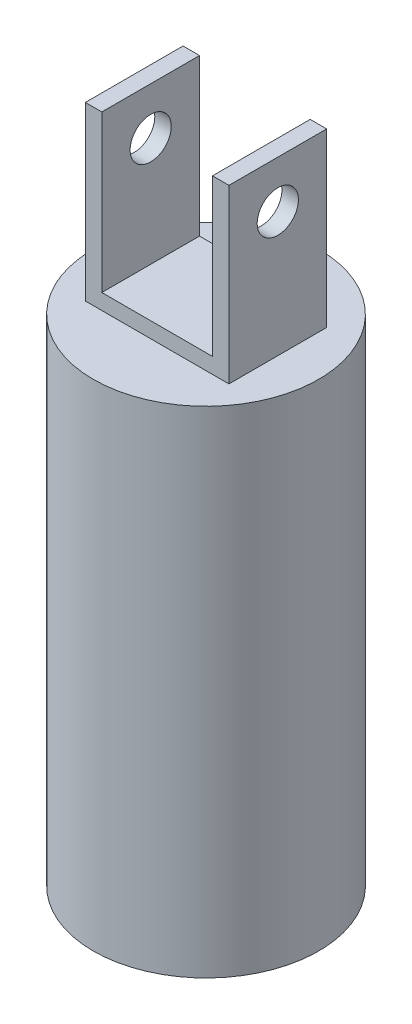
from build123d import *

# Parameters (mm, degrees)
SKETCH1_W           = 4.826
SKETCH1_H           = 25.19045
BOSS_EXTRUDE1_DEPTH = 28.6258
SKETCH2_R           = 25.4
BOSS_EXTRUDE2_DEPTH = 145.034
SKETCH4_R           = 33.02
BOSS_EXTRUDE3_DEPTH = 145.034
SKETCH5_R           = 6.0325
CUT_EXTRUDE2_DEPTH  = 55.0512
SKETCH6_R           = 19.812
CUT_EXTRUDE3_DEPTH  = 106.934


with BuildPart() as part:
    # Sketch1 → Boss-Extrude1 (new body)
    with BuildSketch(Plane.XY):
        Polygon((37.2364, 24.806452693), (42.0624, 24.806452693), (42.0624, 50.3809), (37.2364, 50.3809), (37.2364, 25.19045), align=None)
        Polygon((21.0312, 4.572), (21.0312, 0), (42.0624, 0), (42.0624, 24.806452693), (37.2364, 24.806452693), (37.2364, 4.572), align=None)
        Polygon((0, 0), (21.0312, 0), (21.0312, 4.572), (4.826, 4.572), (4.826, 25.19045), (0, 25.19045), align=None)
        with Locations((2.413, 37.785675)):
            Rectangle(SKETCH1_W, SKETCH1_H)
    extrude(amount=BOSS_EXTRUDE1_DEPTH)

    # Sketch2 → Boss-Extrude2 (add)
    with BuildSketch(Plane.XZ):
        with Locations((21.0312, 14.3129)):
            Circle(SKETCH2_R)
    extrude(amount=BOSS_EXTRUDE2_DEPTH)

    # Sketch4 → Boss-Extrude3 (add)
    with BuildSketch(Plane(origin=(0, 0, 0), x_dir=(1, 0, 0), z_dir=(0, 1, 0))):
        with Locations((21.0312, -14.3129)):
            Circle(SKETCH4_R)
    extrude(amount=-BOSS_EXTRUDE3_DEPTH)

    # Sketch5 → Cut-Extrude2 (cut, through all)
    with BuildSketch(Plane(origin=(42.0624, 0, 0), x_dir=(0, 0, -1), z_dir=(1, 0, 0))):
        with Locations((-14.3129, 36.576)):
            Circle(SKETCH5_R)
    extrude(amount=-CUT_EXTRUDE2_DEPTH, mode=Mode.SUBTRACT)

    # Sketch6 → Cut-Extrude3 (cut)
    with BuildSketch(Plane.XZ.offset(145.034)):
        with Locations((21.0312, 14.3129)):
            Circle(SKETCH6_R)
    extrude(amount=-CUT_EXTRUDE3_DEPTH, mode=Mode.SUBTRACT)


solid = part.part
